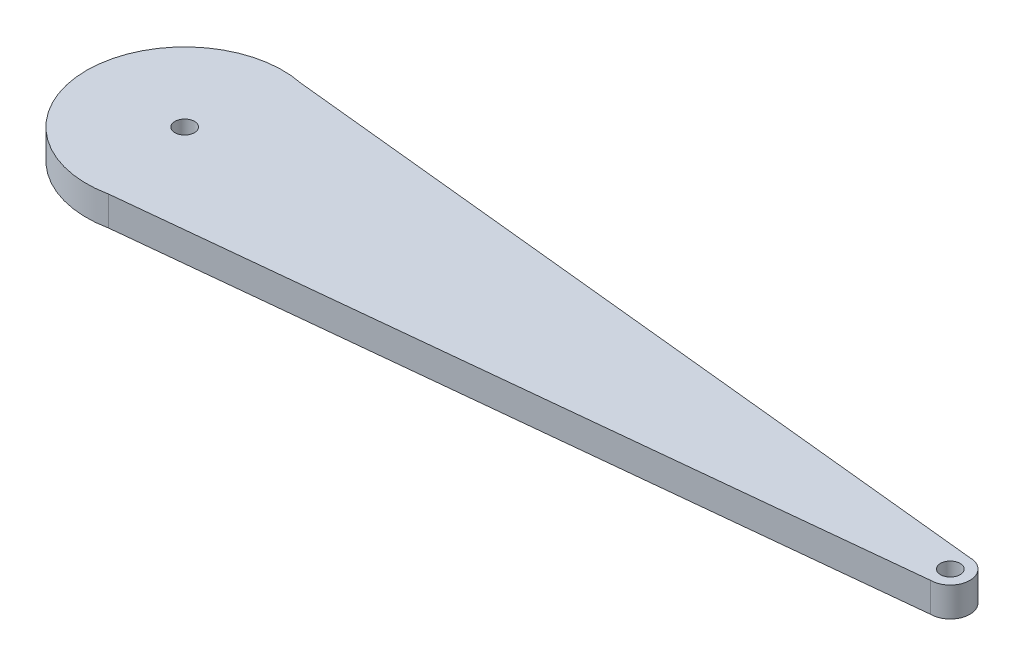
from build123d import *

# Parameters (mm, degrees)
SKETCH1_W           = 90
SKETCH1_H           = 20
BOSS_EXTRUDE1_DEPTH = 3
CUT_EXTRUDE1_DEPTH  = 4
SKETCH3_R           = 1
CUT_EXTRUDE2_DEPTH  = 4


with BuildPart() as part:
    # Sketch1 → Boss-Extrude1 (new body)
    with BuildSketch(Plane(origin=(0, 0, 0), x_dir=(1, 0, 0), z_dir=(0, 1, 0))):
        with Locations((45, 10)):
            Rectangle(SKETCH1_W, SKETCH1_H)
    extrude(amount=BOSS_EXTRUDE1_DEPTH)

    # Sketch2 → Cut-Extrude1 (cut, through all)
    with BuildSketch(Plane(origin=(0, 3, 0), x_dir=(1, 0, 0), z_dir=(0, 1, 0))):
        with BuildLine():
            Line((90, 20), (10, 20))
            ThreePointArc((10, 20), (11.020288655, 19.947814386), (12.029928432, 19.791802212))
            Line((12.029928432, 19.791802212), (88, 12))
            ThreePointArc((88, 12), (89.414213562, 11.414213562), (90, 10))
            Line((90, 10), (90, 20))
        make_face()
        with BuildLine():
            Line((90, 0), (90, 10))
            ThreePointArc((90, 10), (89.414213562, 8.585786438), (88, 8))
            Line((88, 8), (12.029928432, 0.208197788))
            ThreePointArc((12.029928432, 0.208197788), (11.020288655, 0.052185614), (10, 0))
            Line((10, 0), (90, 0))
        make_face()
        with BuildLine():
            ThreePointArc((10, 0), (2.928932188, 2.928932188), (0, 10))
            Line((0, 10), (0, 0))
            Line((0, 0), (10, 0))
        make_face()
        with BuildLine():
            ThreePointArc((0, 10), (2.928932188, 17.071067812), (10, 20))
            Line((10, 20), (0, 20))
            Line((0, 20), (0, 10))
        make_face()
    extrude(amount=-CUT_EXTRUDE1_DEPTH, mode=Mode.SUBTRACT)

    # Sketch3 → Cut-Extrude2 (cut, through all)
    with BuildSketch(Plane(origin=(0, 3, 0), x_dir=(1, 0, 0), z_dir=(0, 1, 0))):
        with Locations((10, 10)):
            Circle(SKETCH3_R)
        with Locations((88, 10)):
            Circle(SKETCH3_R)
    extrude(amount=-CUT_EXTRUDE2_DEPTH, mode=Mode.SUBTRACT)


solid = part.part
